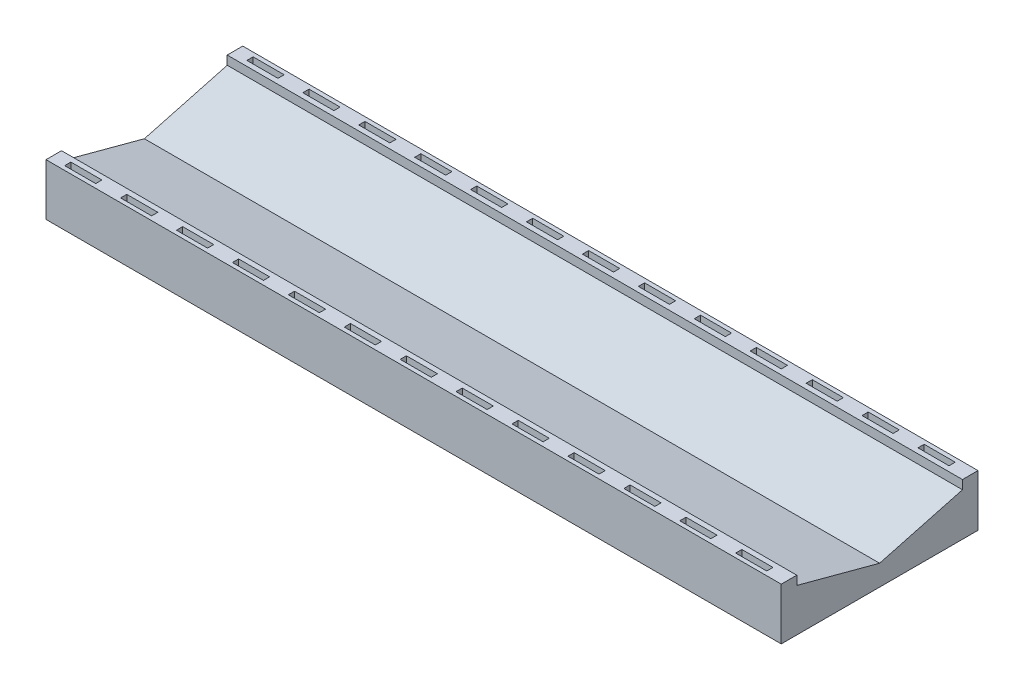
from build123d import *

# Parameters (mm, degrees)
SKETCH1_W               = 38
SKETCH1_H               = 9.5
BOSS_EXTRUDE1_DEPTH     = 2.5
SKETCH2_W               = 1.5
SKETCH2_H               = 0.3
CUT_EXTRUDE1_DEPTH      = 2
LPATTERN1_COUNT         = 14
LPATTERN1_PITCH         = 2.7
LPATTERN1_COUNT_DIR2    = 2
LPATTERN1_PITCH_DIR2    = 8.8
CUT_EXTRUDE2_DEPTH      = 1
CUT_EXTRUDE2_DEPTH_BACK = 39
CUT_EXTRUDE3_DEPTH      = 2.5


with BuildPart() as part:
    # Sketch1 → Boss-Extrude1 (new body)
    with BuildSketch(Plane(origin=(0, 0, 0), x_dir=(1, 0, 0), z_dir=(0, 1, 0))):
        with Locations((19, 4.75)):
            Rectangle(SKETCH1_W, SKETCH1_H)
    extrude(amount=BOSS_EXTRUDE1_DEPTH)

    # Sketch2 → Cut-Extrude1 (cut)
    with BuildSketch(Plane(origin=(0, 2.5, 0), x_dir=(1, 0, 0), z_dir=(0, 1, 0))):
        with Locations((1.25, 0.35)):
            Rectangle(SKETCH2_W, SKETCH2_H)
    cut_extrude1 = extrude(amount=-CUT_EXTRUDE1_DEPTH, mode=Mode.SUBTRACT)

    # LPattern1: Cut-Extrude1 14 × 2
    with Locations(*[(i * LPATTERN1_PITCH, 0, -j * LPATTERN1_PITCH_DIR2) for i in range(LPATTERN1_COUNT) for j in range(LPATTERN1_COUNT_DIR2) if (i, j) != (0, 0)]):
        add(cut_extrude1, mode=Mode.SUBTRACT)

    # Sketch4 → Cut-Extrude2 (cut, two sides)
    with BuildSketch(Plane(origin=(38, 0, 0), x_dir=(0, 0, -1), z_dir=(1, 0, 0))) as cut_extrude2_sk:
        Polygon((0.75, 30.700274723), (0.75, 2.5), (0.75, 2.07179677), (4.75, 1), (8.75, 2.07179677), (8.75, 2.5), (8.75, 30.700274723), (8.75, 87.10082417), (0.75, 87.10082417), align=None)
    extrude(amount=CUT_EXTRUDE2_DEPTH, mode=Mode.SUBTRACT)
    extrude(cut_extrude2_sk.sketch, amount=-CUT_EXTRUDE2_DEPTH_BACK, mode=Mode.SUBTRACT)

    # Sketch5 → Cut-Extrude3 (cut)
    with BuildSketch(Plane.ZY):
        Polygon((-0.75, 2.5), (-0.75, 2.07179677), (-4.75, 1), (-8.75, 2.07179677), (-8.75, 2.5), (-9.5, 2.5), (-9.5, 0), (0, 0), (0, 2.5), align=None)
    extrude(amount=-CUT_EXTRUDE3_DEPTH, mode=Mode.SUBTRACT)


solid = part.part
